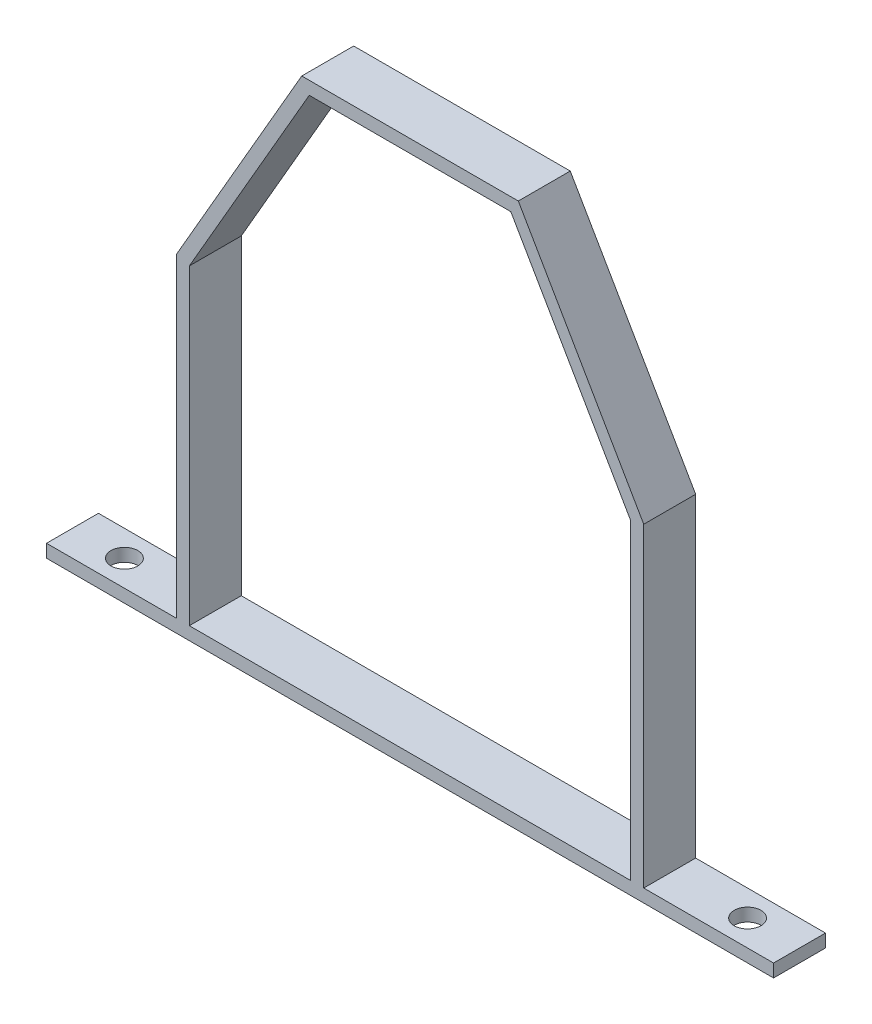
from build123d import *

# Parameters (mm, degrees)
BOSS_EXTRUDE1_DEPTH         = 25.4
F_1_2_CLEARANCE_HOLE1_D     = 13.09624
F_1_2_CLEARANCE_HOLE1_DEPTH = 76.2
F_1_2_CLEARANCE_HOLE1_TIP   = 3.934507437


with BuildPart() as part:
    # Sketch1 → Boss-Extrude1 (new body)
    with BuildSketch(Plane.XY):
        Polygon((0, 0), (-355.6, 0), (-355.6, 6.35), (-292.1, 6.35), (-292.1, 160.451477372), (-230.75738686, 266.7), (-124.84261314, 266.7), (-63.5, 160.451477372), (-63.5, 6.35), (0, 6.35), align=None)
        Polygon((-285.75, 158.75), (-285.75, 6.35), (-69.85, 6.35), (-69.85, 158.75), (-128.50878735, 260.35), (-227.09121265, 260.35), align=None, mode=Mode.SUBTRACT)
    extrude(amount=BOSS_EXTRUDE1_DEPTH)

    # 1/2 Clearance Hole1
    with Locations(Plane(origin=(0, 0, 0), x_dir=(-1, 0, 0), z_dir=(0, -1, 0))):
        with Locations((25.4, -12.7), (330.2, -12.7)):
            Hole(F_1_2_CLEARANCE_HOLE1_D / 2, depth=F_1_2_CLEARANCE_HOLE1_DEPTH)
            with Locations((0, 0, -(F_1_2_CLEARANCE_HOLE1_DEPTH + F_1_2_CLEARANCE_HOLE1_TIP / 2))):  # 118° drill point
                Cone(0, F_1_2_CLEARANCE_HOLE1_D / 2, F_1_2_CLEARANCE_HOLE1_TIP, mode=Mode.SUBTRACT)


solid = part.part
